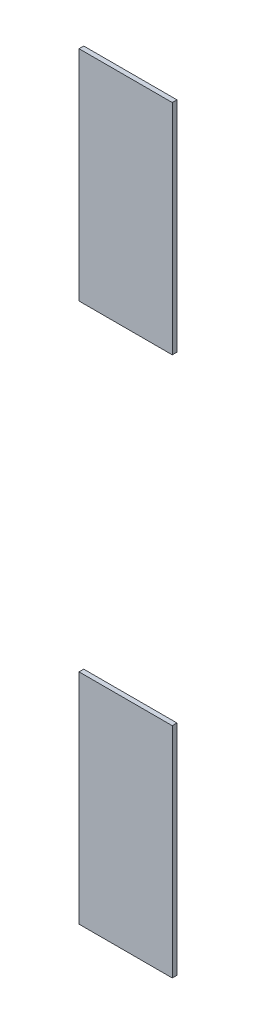
from build123d import *

# Parameters (mm, degrees)
SKETCH_1_W        = 2.974998474
SKETCH_1_H        = 6.974998474
EXTRUDE_1_DEPTH   = 0.15
EXTRUDE_1_2_DEPTH = 0.15


with BuildPart() as part:
    # Эскиз1 → Бобышка-Вытянуть1 (new body)
    with BuildSketch(Plane(origin=(0, 0, 0), x_dir=(-1, 0, 0), z_dir=(0, 0, -1))):
        with Locations((-31.0625, 46.737499237)):
            Rectangle(SKETCH_1_W, SKETCH_1_H)
    extrude(amount=-EXTRUDE_1_DEPTH)


with BuildPart() as body_2:
    # Эскиз1 → Extrude 1 2 (new body)
    with BuildSketch(Plane(origin=(0, 0, 0), x_dir=(-1, 0, 0), z_dir=(0, 0, -1))):
        with Locations((-31.0625, 29.512500763)):
            Rectangle(SKETCH_1_W, SKETCH_1_H)
    extrude(amount=-EXTRUDE_1_2_DEPTH)


solid = Compound([part.part, body_2.part])
